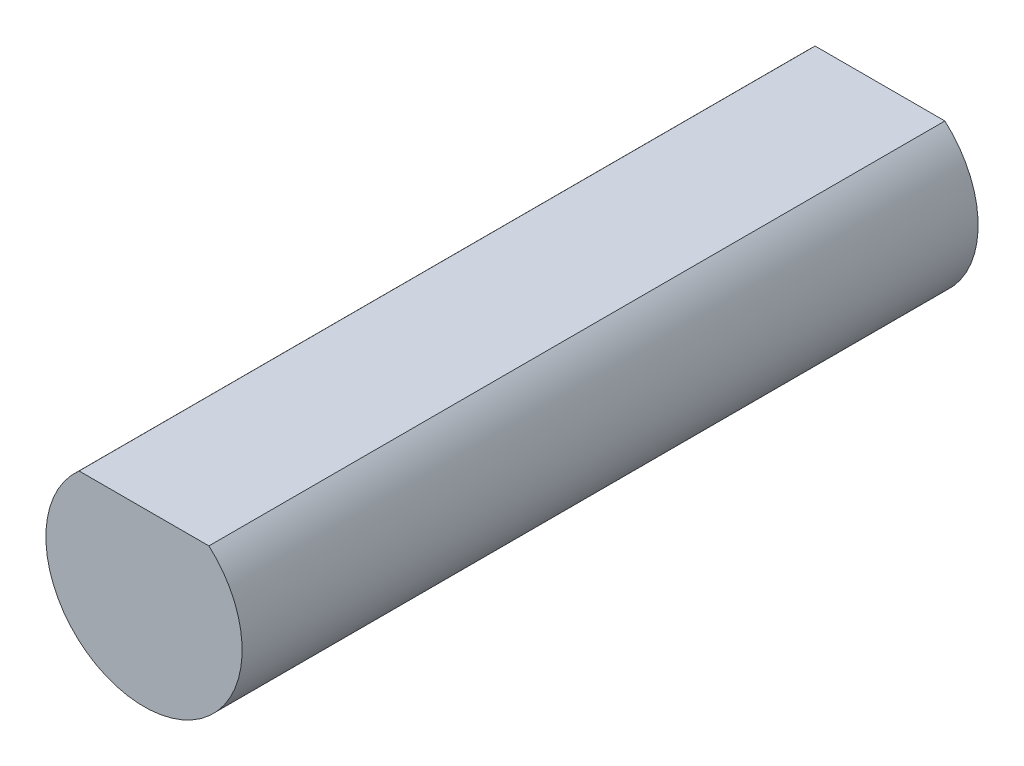
from build123d import *

# Parameters (mm, degrees)
BOSS_EXTRUDE1_DEPTH = 15


with BuildPart() as part:
    # Sketch1 → Boss-Extrude1 (new body)
    with BuildSketch(Plane.XY):
        with BuildLine():
            Line((-1.322875656, 1.5), (1.322875656, 1.5))
            ThreePointArc((1.322875656, 1.5), (0, -2), (-1.322875656, 1.5))
        make_face()
    extrude(amount=BOSS_EXTRUDE1_DEPTH)


solid = part.part
